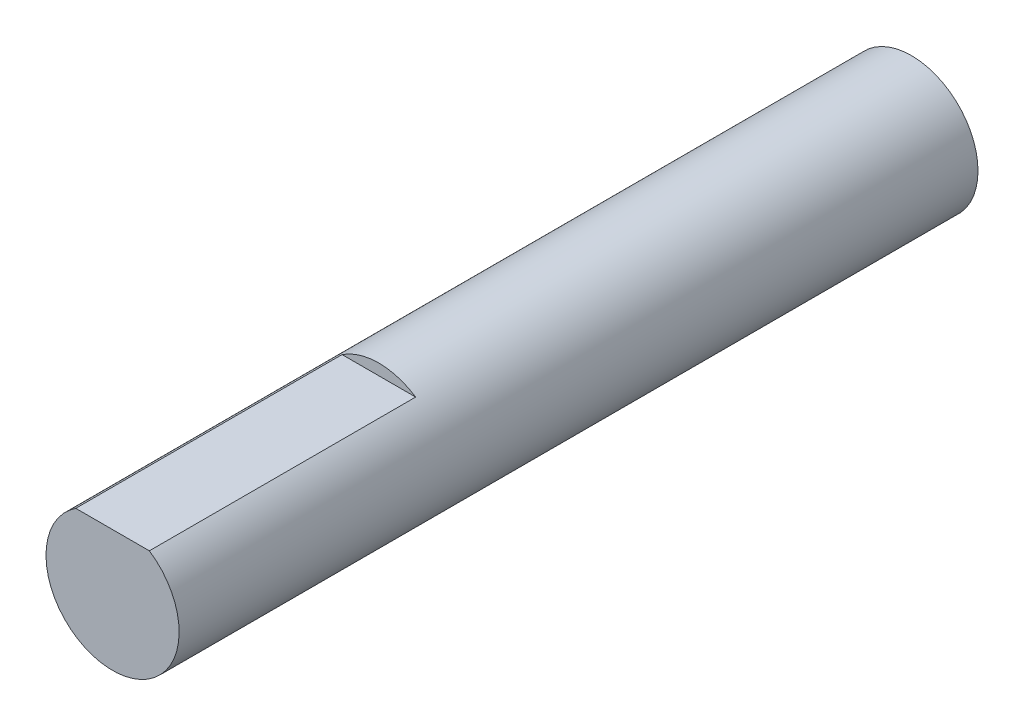
from build123d import *

# Parameters (mm, degrees)
SKETCH_1_R          = 3
EXTRUDE_1_DEPTH     = 36
CUT_EXTRUDE_2_DEPTH = 12


with BuildPart() as part:
    # 草图1 → 凸台-拉伸1 (new body)
    with BuildSketch(Plane.XY):
        Circle(SKETCH_1_R)
    extrude(amount=EXTRUDE_1_DEPTH)

    # 草图2 → 切除-拉伸2 (cut)
    with BuildSketch(Plane.XY.offset(36)):
        with BuildLine():
            Line((-1.658312395, 2.5), (1.658312395, 2.5))
            ThreePointArc((1.658312395, 2.5), (0, 3), (-1.658312395, 2.5))
        make_face()
    extrude(amount=-CUT_EXTRUDE_2_DEPTH, mode=Mode.SUBTRACT)


solid = part.part
